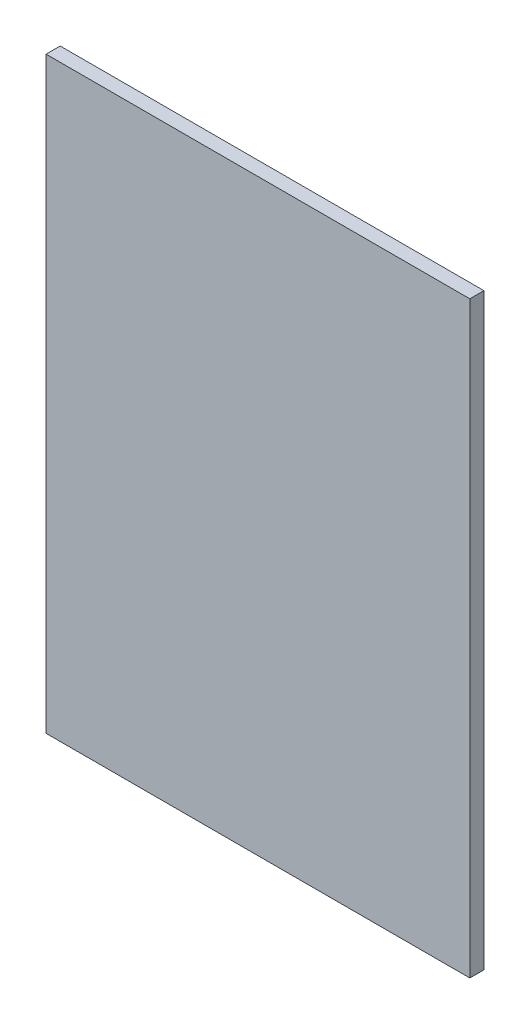
from build123d import *

# Parameters (mm, degrees)
SKETCH_1_W      = 300
SKETCH_1_H      = 416.427331112
EXTRUDE_1_DEPTH = 10


with BuildPart() as part:
    # 草图1 → 凸台-拉伸1 (new body)
    with BuildSketch(Plane.XY):
        with Locations((-198.542768428, 241.474836236)):
            Rectangle(SKETCH_1_W, SKETCH_1_H)
    extrude(amount=EXTRUDE_1_DEPTH)


solid = part.part
